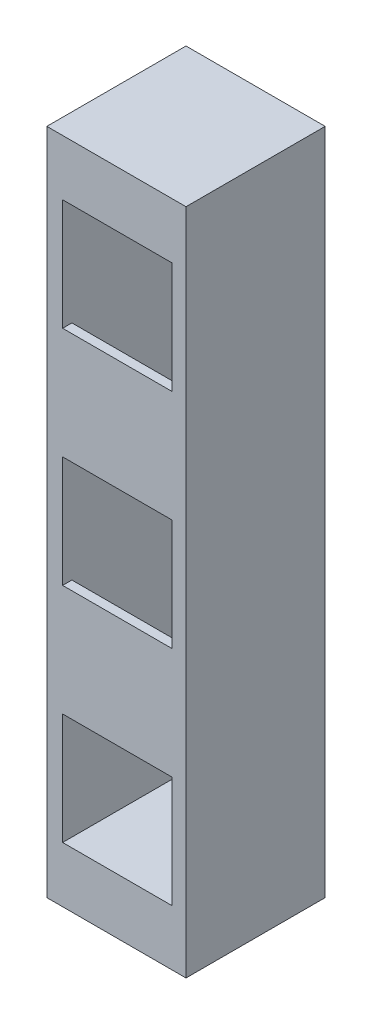
from build123d import *

# Parameters (mm, degrees)
CROQUIS1_W              = 190.5
CROQUIS1_H              = 914.4
SALIENTE_EXTRUIR1_DEPTH = 95.25
CROQUIS2_W              = 149.86
CROQUIS2_H              = 152.4
CORTAR_EXTRUIR1_DEPTH   = 177.8
CORTAR_EXTRUIR3_START   = 152.4
CROQUIS3_W              = 149.86
CROQUIS3_H              = 165.1
CORTAR_EXTRUIR3_DEPTH   = 457.2


with BuildPart() as part:
    # Croquis1 → Saliente-Extruir1 (new body, symmetric)
    with BuildSketch(Plane.XY):
        Rectangle(CROQUIS1_W, CROQUIS1_H)
    extrude(amount=SALIENTE_EXTRUIR1_DEPTH, both=True)

    # Croquis2 → Cortar-Extruir1 (cut)
    with BuildSketch(Plane.XY.offset(95.25)):
        with Locations((1.27, 304.8)):
            Rectangle(CROQUIS2_W, CROQUIS2_H)
        with Locations((1.27, 0)):
            Rectangle(CROQUIS2_W, CROQUIS2_H)
        with Locations((1.27, -304.8)):
            Rectangle(CROQUIS2_W, CROQUIS2_H)
    extrude(amount=-CORTAR_EXTRUIR1_DEPTH, mode=Mode.SUBTRACT)

    # Croquis3 → Cortar-Extruir3 (cut)
    with BuildSketch(Plane.XZ.offset(-381).offset(CORTAR_EXTRUIR3_START)):
        with Locations((1.27, 0)):
            Rectangle(CROQUIS3_W, CROQUIS3_H)
    extrude(amount=CORTAR_EXTRUIR3_DEPTH, mode=Mode.SUBTRACT)


solid = part.part
